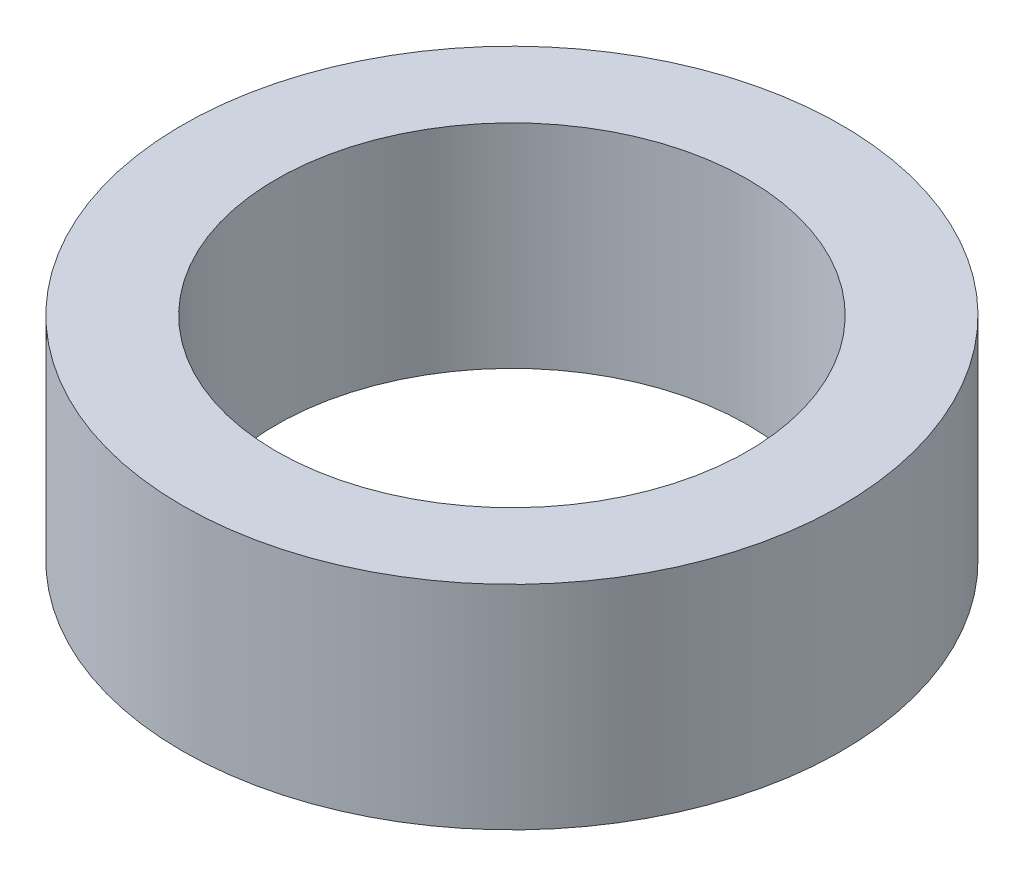
from build123d import *

# Parameters (mm, degrees)
SKETCH1_R           = 4.65
SKETCH1_R_2         = 3.325
BOSS_EXTRUDE1_DEPTH = 3


with BuildPart() as part:
    # Sketch1 → Boss-Extrude1 (new body)
    with BuildSketch(Plane(origin=(0, 0, 0), x_dir=(1, 0, 0), z_dir=(0, 1, 0))):
        Circle(SKETCH1_R)
        Circle(SKETCH1_R_2, mode=Mode.SUBTRACT)
    extrude(amount=BOSS_EXTRUDE1_DEPTH)


solid = part.part
